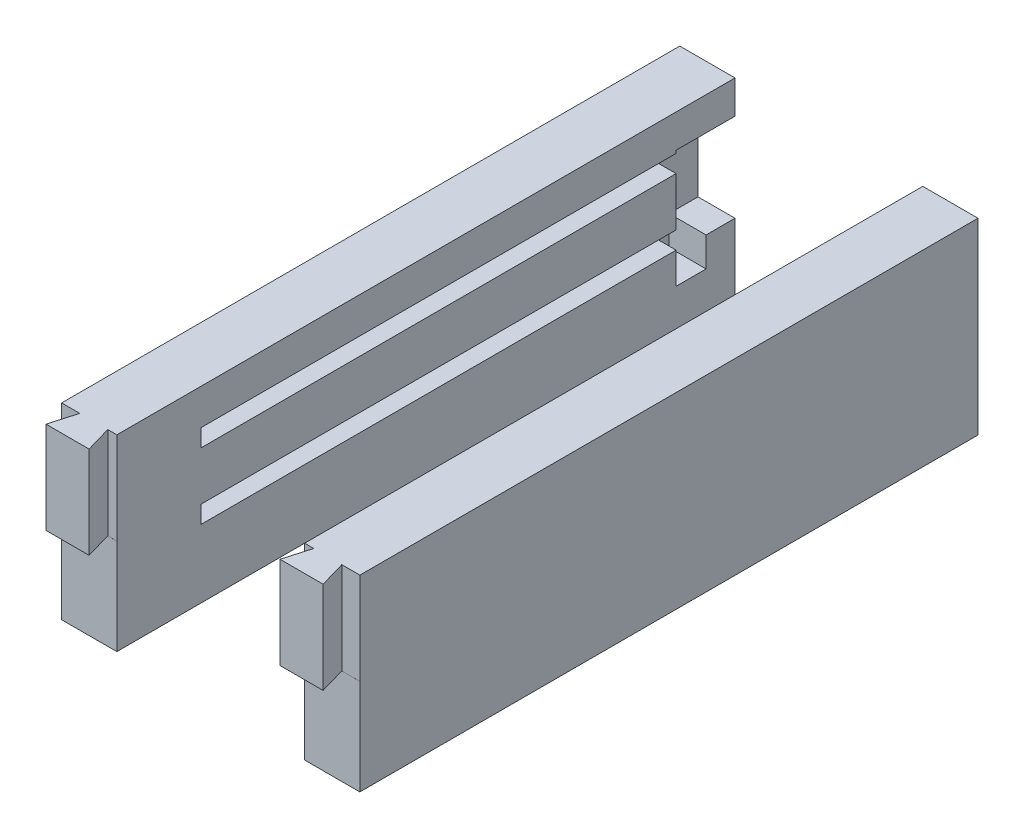
from build123d import *

# Parameters (mm, degrees)
SKETCH1_W           = 175
SKETCH1_H           = 51
BOSS_EXTRUDE1_DEPTH = 15
SKETCH7_W           = 4.75
SKETCH7_H           = 4.75
CUT_EXTRUDE5_DEPTH  = 145
SKETCH10_W          = 10.05
SKETCH10_H          = 24
CUT_EXTRUDE6_DEPTH  = 16
SKETCH11_W          = 10.05
SKETCH11_H          = 8.15
CUT_EXTRUDE7_DEPTH  = 8
CUT_EXTRUDE8_DEPTH  = 25
SKETCH13_W          = 15
SKETCH13_H          = 7.11
CUT_EXTRUDE9_DEPTH  = 26


with BuildPart() as part:
    # Sketch1 → Boss-Extrude1 (new body)
    with BuildSketch(Plane(origin=(0, 0, 0), x_dir=(0, 0, -1), z_dir=(1, 0, 0))):
        with Locations((22.937921078, 5.057266603)):
            Rectangle(SKETCH1_W, SKETCH1_H)
    extrude(amount=BOSS_EXTRUDE1_DEPTH)

    # Sketch7 → Cut-Extrude5 (cut)
    with BuildSketch(Plane(origin=(0, 0, -110.437921078), x_dir=(-1, 0, 0), z_dir=(0, 0, -1))):
        with Locations((-12.625, 0.432266603)):
            Rectangle(SKETCH7_W, SKETCH7_H)
        with Locations((-12.625, 18.432266603)):
            Rectangle(SKETCH7_W, SKETCH7_H)
    extrude(amount=-CUT_EXTRUDE5_DEPTH, mode=Mode.SUBTRACT)

    # Sketch10 → Cut-Extrude6 (cut)
    with BuildSketch(Plane(origin=(0, 0, -110.437921078), x_dir=(-1, 0, 0), z_dir=(0, 0, -1))):
        with Locations((-9.975, 9.557266603)):
            Rectangle(SKETCH10_W, SKETCH10_H)
    extrude(amount=-CUT_EXTRUDE6_DEPTH, mode=Mode.SUBTRACT)

    # Sketch11 → Cut-Extrude7 (cut)
    with BuildSketch(Plane(origin=(0, -2.442733397, 0), x_dir=(1, 0, 0), z_dir=(0, 1, 0))):
        with Locations((9.975, 98.512921078)):
            Rectangle(SKETCH11_W, SKETCH11_H)
    extrude(amount=-CUT_EXTRUDE7_DEPTH, mode=Mode.SUBTRACT)

    # Sketch12 → Cut-Extrude8 (cut)
    with BuildSketch(Plane(origin=(0, 30.557266603, 0), x_dir=(1, 0, 0), z_dir=(0, 1, 0))):
        Polygon((0, -57.448742372), (4.909716433, -57.448742372), (2.87, -64.562078922), (0, -64.562078922), align=None)
        Polygon((15, -57.448742372), (15, -64.562078922), (14.57, -64.562078922), (12.530283567, -57.448742372), align=None)
    extrude(amount=-CUT_EXTRUDE8_DEPTH, mode=Mode.SUBTRACT)

    # Sketch13 → Cut-Extrude9 (cut)
    with BuildSketch(Plane.XZ.offset(20.442733397)):
        with Locations((7.5, 61.007078922)):
            Rectangle(SKETCH13_W, SKETCH13_H)
    extrude(amount=-CUT_EXTRUDE9_DEPTH, mode=Mode.SUBTRACT)


with BuildPart() as body_2:
    # Mirror4: mirrored copy
    add(part.part.mirror(Plane(origin=(40.5, 0, 0), x_dir=(0, 0, 1), z_dir=(1, 0, 0))))


solid = Compound([part.part, body_2.part])
